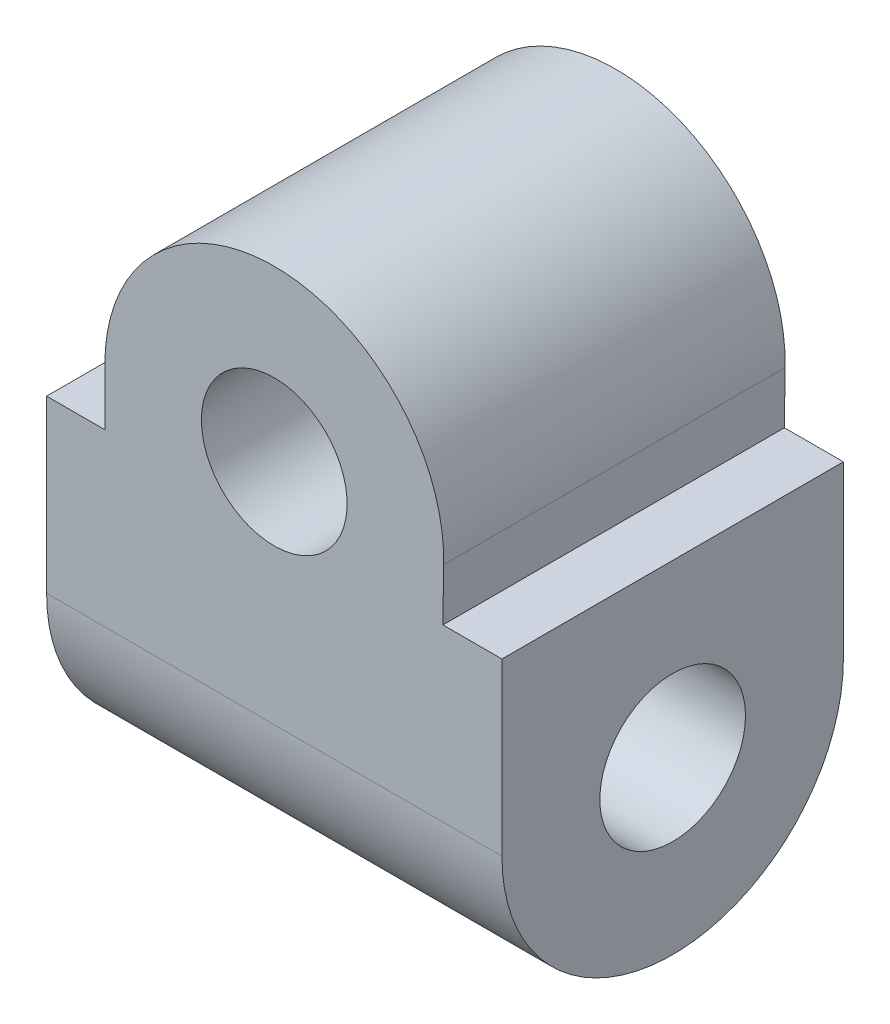
from build123d import *

# Parameters (mm, degrees)
SKETCH1_R           = 6.4
BOSS_EXTRUDE1_DEPTH = 40
SKETCH3_R           = 6.4
CUT_EXTRUDE1_DEPTH  = 43


with BuildPart() as part:
    # Sketch1 → Boss-Extrude1 (new body)
    with BuildSketch(Plane(origin=(0, 0, 0), x_dir=(0, 0, -1), z_dir=(1, 0, 0))):
        with BuildLine():
            Line((15, 0), (15, 35))
            Line((15, 35), (-15, 35))
            Line((-15, 35), (-15, 0))
            ThreePointArc((-15, 0), (0, -15), (15, 0))
        make_face()
        Circle(SKETCH1_R, mode=Mode.SUBTRACT)
    extrude(amount=BOSS_EXTRUDE1_DEPTH)

    # Sketch3 → Cut-Extrude1 (cut)
    with BuildSketch(Plane(origin=(0, 0, -15), x_dir=(-1, 0, 0), z_dir=(0, 0, -1))):
        with Locations((-20, 20)):
            Circle(SKETCH3_R)
        with BuildLine():
            Line((-46.007478206, 15), (-34.81696458, 15))
            Line((-34.81696458, 15), (-34.877252069, 19.610892924))
            ThreePointArc((-34.877252069, 19.610892924), (-20.194570167, 34.8810677), (-5.11766035, 20))
            Line((-5.11766035, 20), (-5.11766035, 15))
            Line((-5.11766035, 15), (8.555205081, 15))
            Line((8.555205081, 15), (8.555205081, 43.038004213))
            Line((8.555205081, 43.038004213), (-46.007478206, 43.038004213))
            Line((-46.007478206, 43.038004213), (-46.007478206, 15))
        make_face()
    extrude(amount=-CUT_EXTRUDE1_DEPTH, mode=Mode.SUBTRACT)


solid = part.part
